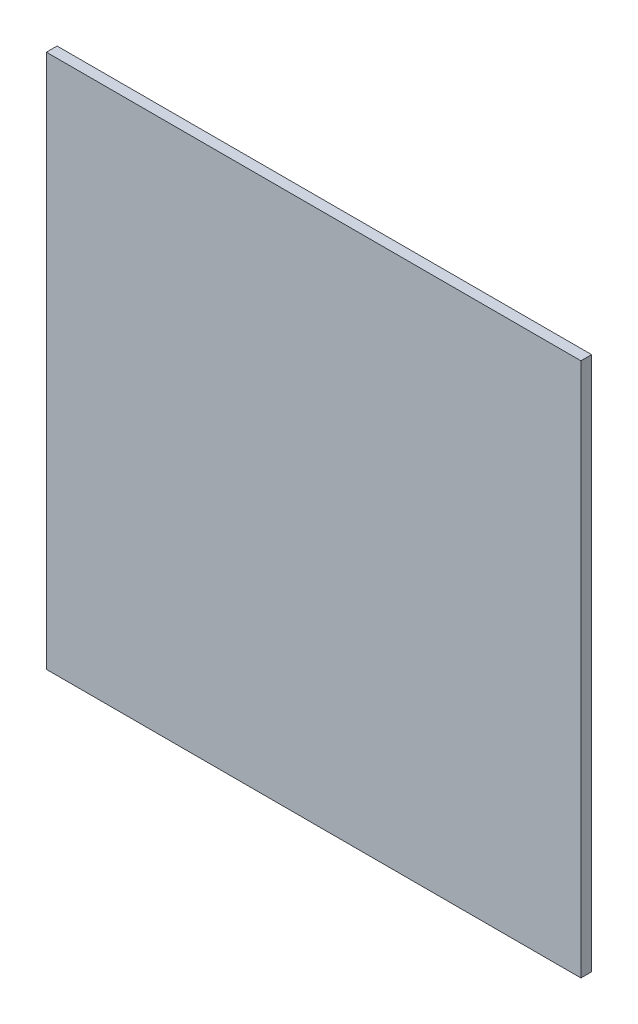
from build123d import *

# Parameters (mm, degrees)
SKETCH1_W           = 50
SKETCH1_H           = 50
BOSS_EXTRUDE1_DEPTH = 1


with BuildPart() as part:
    # Sketch1 → Boss-Extrude1 (new body)
    with BuildSketch(Plane.XY):
        with Locations((25, 25)):
            Rectangle(SKETCH1_W, SKETCH1_H)
    extrude(amount=BOSS_EXTRUDE1_DEPTH)


solid = part.part
